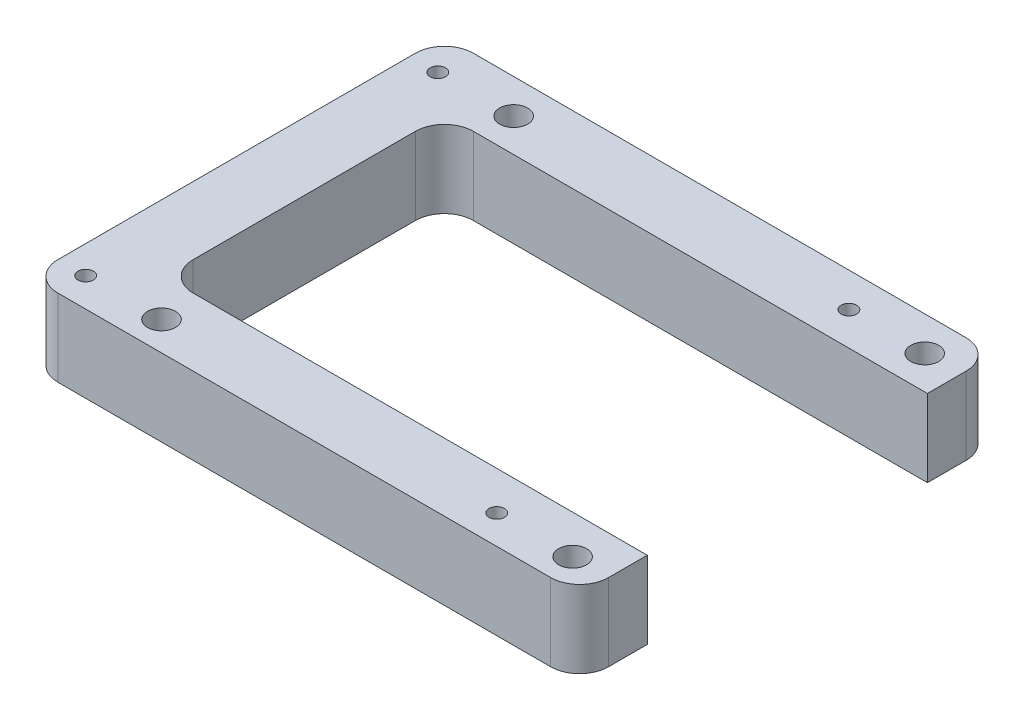
from build123d import *

# Parameters (mm, degrees)
SKETCH1_W                      = 57
SKETCH1_H                      = 43
BOSS_EXTRUDE1_DEPTH            = 8
SKETCH2_W                      = 50
SKETCH2_H                      = 29
CUT_EXTRUDE1_DEPTH             = 8
FILLET1_R                      = 3
M2X0_4_TAPPED_HOLE1_D          = 1.6
CBORE_FOR_M2_SHCS1_D           = 2.9
CBORE_FOR_M2_SHCS1_CBORE_D     = 4.9
CBORE_FOR_M2_SHCS1_CBORE_DEPTH = 5.5


with BuildPart() as part:
    # Sketch1 → Boss-Extrude1 (new body)
    with BuildSketch(Plane(origin=(0, 0, 0), x_dir=(1, 0, 0), z_dir=(0, 1, 0))):
        Rectangle(SKETCH1_W, SKETCH1_H)
    extrude(amount=BOSS_EXTRUDE1_DEPTH)

    # Sketch2 → Cut-Extrude1 (cut)
    with BuildSketch(Plane(origin=(0, 0, 0), x_dir=(1, 0, 0), z_dir=(0, 1, 0))):
        with Locations((3.5, 0)):
            Rectangle(SKETCH2_W, SKETCH2_H)
    extrude(amount=CUT_EXTRUDE1_DEPTH, mode=Mode.SUBTRACT)

    # Fillet1
    fillet1_edges = [part.edges().sort_by_distance(p)[0] for p in [
        (-21.5, 4, -14.5),
        (-21.5, 4, 14.5),
        (-28.5, 4, -21.5),
        (-28.5, 4, 21.5),
        (28.5, 4, 21.5),
        (28.5, 4, -21.5),
    ]]
    fillet(fillet1_edges, radius=FILLET1_R)

    # M2x0.4 Tapped Hole1 (through all)
    with Locations(Plane(origin=(0, 0, 0), x_dir=(-1, 0, 0), z_dir=(0, -1, 0))):
        with Locations((25.63, 17.95), (25.63, -18.5), (-16.92, -18.5), (-16.92, 17.95)):
            Hole(M2X0_4_TAPPED_HOLE1_D / 2)

    # CBORE for M2 SHCS1 (through all)
    with Locations(Plane(origin=(0, 0, 0), x_dir=(-1, 0, 0), z_dir=(0, -1, 0))):
        with Locations((-24.77, 17.95), (17.78, 17.95), (17.78, -18.5), (-24.77, -18.5)):
            CounterBoreHole(CBORE_FOR_M2_SHCS1_D / 2, CBORE_FOR_M2_SHCS1_CBORE_D / 2, CBORE_FOR_M2_SHCS1_CBORE_DEPTH)


solid = part.part
